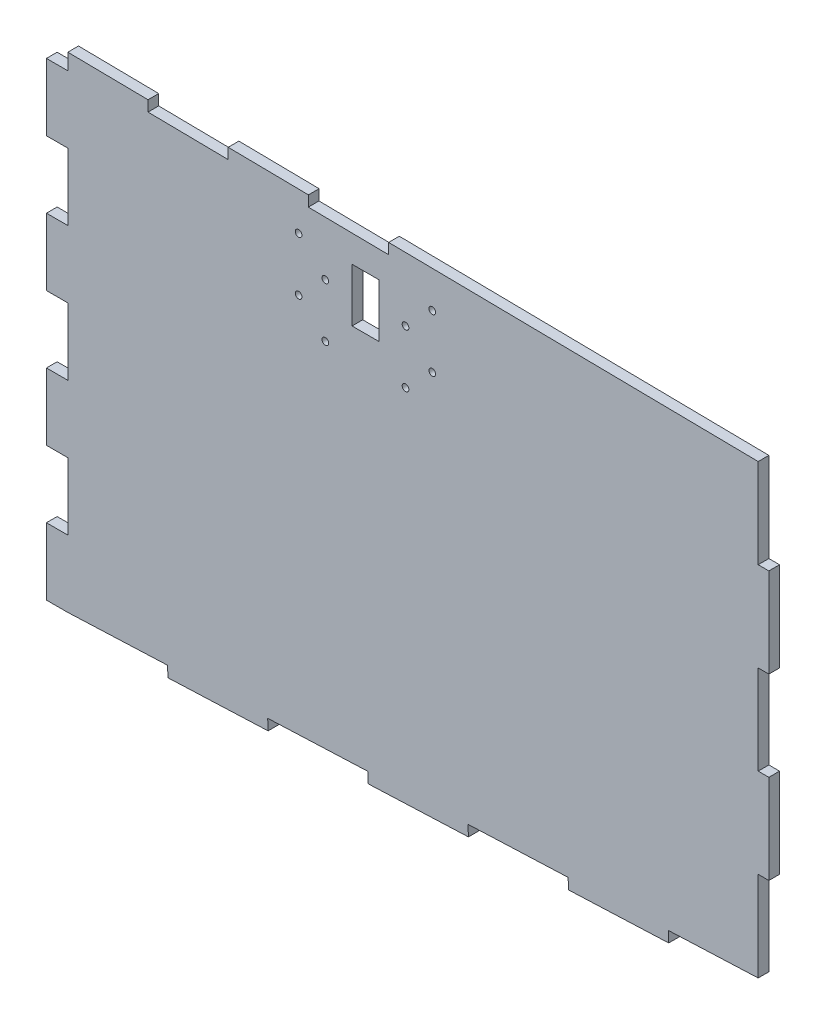
from build123d import *

# Parameters (mm, degrees)
BOSS_EXTRUDE1_DEPTH = 10.16
CUT_EXTRUDE1_DEPTH  = 11.16
SKETCH4_W           = 129.547530324
SKETCH4_H           = 444.037072
CUT_EXTRUDE3_DEPTH  = 11.16
SKETCH5_W           = 10.16
SKETCH5_H           = 84.922739191
CUT_EXTRUDE5_DEPTH  = 11.16
CUT_EXTRUDE6_DEPTH  = 11.16
SKETCH11_R          = 3.175
SKETCH11_W          = 25.4
SKETCH11_H          = 50.8
CUT_EXTRUDE8_DEPTH  = 11.16


with BuildPart() as part:
    # Sketch1 → Boss-Extrude1 (new body)
    with BuildSketch(Plane.XY):
        with BuildLine():
            Line((20.32, 73.849956434), (0, 73.849956434))
            Line((0, 73.849956434), (0, 10.164894956))
            Line((0, 10.164894956), (20.32, 10.164894956))
            Line((20.32, 10.164894956), (115.06781826, 14.091181531))
            Line((115.06781826, 14.091181531), (115.488322648, 3.943711998))
            Line((115.488322648, 3.943711998), (210.656645296, 7.887423995))
            Line((210.656645296, 7.887423995), (210.236140908, 18.034893528))
            Line((210.236140908, 18.034893528), (305.404463556, 21.978605526))
            Line((305.404463556, 21.978605526), (305.824967945, 11.831135993))
            Line((305.824967945, 11.831135993), (400.993290593, 15.77484799))
            Line((400.993290593, 15.77484799), (400.572786204, 25.922317523))
            Line((400.572786204, 25.922317523), (495.741108852, 29.866029521))
            Line((495.741108852, 29.866029521), (496.161613241, 19.718559988))
            Line((496.161613241, 19.718559988), (591.329935889, 23.662271985))
            Line((591.329935889, 23.662271985), (590.909431501, 33.809741518))
            Line((590.909431501, 33.809741518), (686.077754149, 37.753453516))
            Line((686.077754149, 37.753453516), (686.498258538, 27.605983983))
            Line((686.498258538, 27.605983983), (781.666581186, 31.54969598))
            Line((781.666581186, 31.54969598), (781.246076797, 41.697165514))
            Line((781.246076797, 41.697165514), (781.246076797, 471.95159927))
            ThreePointArc((781.246076797, 471.95159927), (401.049995582, 500.057636465), (20.32, 519.645386783))
            Line((20.32, 519.645386783), (20.32, 455.960325305))
            Line((20.32, 455.960325305), (0, 455.960325305))
            Line((0, 455.960325305), (0, 392.275263826))
            Line((0, 392.275263826), (20.32, 392.275263826))
            Line((20.32, 392.275263826), (20.32, 328.590202348))
            Line((20.32, 328.590202348), (0, 328.590202348))
            Line((0, 328.590202348), (0, 264.905140869))
            Line((0, 264.905140869), (20.32, 264.905140869))
            Line((20.32, 264.905140869), (20.32, 201.220079391))
            Line((20.32, 201.220079391), (0, 201.220079391))
            Line((0, 201.220079391), (0, 137.535017912))
            Line((0, 137.535017912), (20.32, 137.535017912))
            Line((20.32, 137.535017912), (20.32, 73.849956434))
        make_face()
    extrude(amount=BOSS_EXTRUDE1_DEPTH)

    # Sketch2 → Cut-Extrude1 (cut, through all)
    with BuildSketch(Plane.XY.offset(10.16)):
        Polygon((20.32, 471.23904919), (781.246076797, 460.948390721), (781.246076797, 535.017906983), (20.32, 535.017906983), align=None)
    extrude(amount=-CUT_EXTRUDE1_DEPTH, mode=Mode.SUBTRACT)

    # Sketch4 → Cut-Extrude3 (cut, through all)
    with BuildSketch(Plane(origin=(0, 0, 0), x_dir=(-1, 0, 0), z_dir=(0, 0, -1))):
        with Locations((-751.2720237, 249.624519983)):
            Rectangle(SKETCH4_W, SKETCH4_H)
    extrude(amount=-CUT_EXTRUDE3_DEPTH, mode=Mode.SUBTRACT)

    # Sketch5 → Cut-Extrude5 (cut, through all)
    with BuildSketch(Plane(origin=(0, 0, 0), x_dir=(-1, 0, 0), z_dir=(0, 0, -1))):
        Polygon((-686.498258538, 122.676192707), (-686.498258538, 37.753453516), (-686.077754149, 37.753453516), (-676.338258538, 37.753453516), (-676.338258538, 122.676192707), align=None)
        with Locations((-681.418258538, 250.060301493)):
            Rectangle(SKETCH5_W, SKETCH5_H)
        Polygon((-686.498258538, 462.229747042), (-686.498258538, 377.444410279), (-676.338258538, 377.444410279), (-676.338258538, 462.367149469), align=None)
        Polygon((-676.338258538, 37.349855295), (-686.077754149, 37.753453516), (-686.498258538, 27.605983983), (-686.498258538, 26.157835014), (-676.338258538, 26.157835014), align=None)
        Polygon((-686.077754149, 37.753453516), (-686.498258538, 37.753453516), (-686.498258538, 27.605983983), align=None)
        Polygon((-676.338258538, 37.753453516), (-686.077754149, 37.753453516), (-676.338258538, 37.349855295), align=None)
    extrude(amount=-CUT_EXTRUDE5_DEPTH, mode=Mode.SUBTRACT)

    # Sketch9 → Cut-Extrude6 (cut, through all)
    with BuildSketch(Plane(origin=(0, 0, 0), x_dir=(-1, 0, 0), z_dir=(0, 0, -1))):
        Polygon((-248.83741583, 457.991507139), (-248.974805694, 468.150578161), (-325.167838357, 467.12015418), (-325.030448493, 456.961083159), align=None)
        Polygon((-96.52, 470.208530984), (-96.52, 460.048530984), (-172.713032663, 459.018107004), (-172.713032663, 469.178107004), align=None)
    extrude(amount=-CUT_EXTRUDE6_DEPTH, mode=Mode.SUBTRACT)

    # Sketch11 → Cut-Extrude8 (cut, through all)
    with BuildSketch(Plane.XY.offset(10.16)):
        with Locations((366.619369126, 431.770831078)):
            Circle(SKETCH11_R)
        with Locations((366.619369126, 380.970831078)):
            Circle(SKETCH11_R)
        with Locations((239.619369126, 431.770831078)):
            Circle(SKETCH11_R)
        with Locations((239.619369126, 380.970831078)):
            Circle(SKETCH11_R)
        with Locations((265.019369126, 406.370831078)):
            Circle(SKETCH11_R)
        with Locations((341.219369126, 406.370831078)):
            Circle(SKETCH11_R)
        with Locations((265.019369126, 355.570831078)):
            Circle(SKETCH11_R)
        with Locations((341.219369126, 355.570831078)):
            Circle(SKETCH11_R)
        with Locations((303.119369126, 406.370831078)):
            Rectangle(SKETCH11_W, SKETCH11_H)
    extrude(amount=-CUT_EXTRUDE8_DEPTH, mode=Mode.SUBTRACT)


solid = part.part
